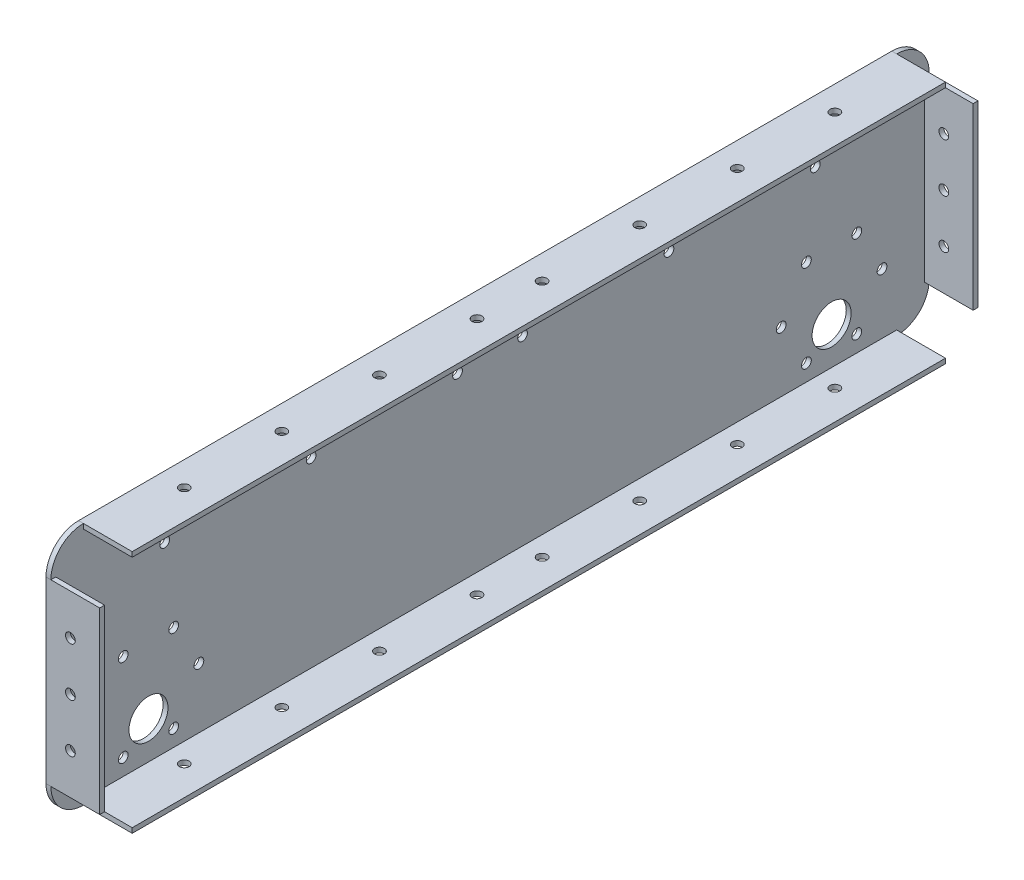
from build123d import *

# Parameters (mm, degrees)
SKETCH1_R           = 1.5
SKETCH1_R_2         = 6
BOSS_EXTRUDE1_DEPTH = 1.5
SKETCH2_W           = 1.5
SKETCH2_H           = 55
BOSS_EXTRUDE2_DEPTH = 15
SKETCH4_R           = 1.5
CUT_EXTRUDE1_DEPTH  = 10
SKETCH6_R           = 1.5
CUT_EXTRUDE2_DEPTH  = 76
SKETCH8_R           = 1.5
CUT_EXTRUDE3_DEPTH  = 271


with BuildPart() as part:
    # Sketch1 → Boss-Extrude1 (new body)
    with BuildSketch(Plane(origin=(0, 0, 0), x_dir=(0, 0, -1), z_dir=(1, 0, 0))):
        with BuildLine():
            Line((-125, 37.5), (125, 37.5))
            ThreePointArc((125, 37.5), (132.071067812, 34.571067812), (135, 27.5))
            Line((135, 27.5), (135, -27.5))
            ThreePointArc((135, -27.5), (132.071067812, -34.571067812), (125, -37.5))
            Line((125, -37.5), (-125, -37.5))
            ThreePointArc((-125, -37.5), (-132.071067812, -34.571067812), (-135, -27.5))
            Line((-135, -27.5), (-135, 27.5))
            ThreePointArc((-135, 27.5), (-132.071067812, 34.571067812), (-125, 37.5))
        make_face()
        with Locations((-112.75, -4.076606241)):
            Circle(SKETCH1_R, mode=Mode.SUBTRACT)
        with Locations((-120.5, -17.5)):
            Circle(SKETCH1_R, mode=Mode.SUBTRACT)
        with Locations((-97.25, -4.076606241)):
            Circle(SKETCH1_R, mode=Mode.SUBTRACT)
        with Locations((-105, -24.5)):
            Circle(SKETCH1_R_2, mode=Mode.SUBTRACT)
        with Locations((-89.5, -17.5)):
            Circle(SKETCH1_R, mode=Mode.SUBTRACT)
        with Locations((-97.25, -30.923393759)):
            Circle(SKETCH1_R, mode=Mode.SUBTRACT)
        with Locations((-112.75, -30.923393759)):
            Circle(SKETCH1_R, mode=Mode.SUBTRACT)
        with Locations((112.75, -30.923393759)):
            Circle(SKETCH1_R, mode=Mode.SUBTRACT)
        with Locations((120.5, -17.5)):
            Circle(SKETCH1_R, mode=Mode.SUBTRACT)
        with Locations((105, -24.5)):
            Circle(SKETCH1_R_2, mode=Mode.SUBTRACT)
        with Locations((97.25, -30.923393759)):
            Circle(SKETCH1_R, mode=Mode.SUBTRACT)
        with Locations((89.5, -17.5)):
            Circle(SKETCH1_R, mode=Mode.SUBTRACT)
        with Locations((97.25, -4.076606241)):
            Circle(SKETCH1_R, mode=Mode.SUBTRACT)
        with Locations((112.75, -4.076606241)):
            Circle(SKETCH1_R, mode=Mode.SUBTRACT)
    extrude(amount=BOSS_EXTRUDE1_DEPTH)

    # Sketch2 → Boss-Extrude2 (add)
    with BuildSketch(Plane(origin=(1.5, 0, 0), x_dir=(0, 0, -1), z_dir=(1, 0, 0))):
        Polygon((-90, 36), (-125, 36), (-125, 37.5), (-90, 37.5), (0, 37.5), (90, 37.5), (125, 37.5), (125, 36), (90, 36), align=None)
        Polygon((90, -37.5), (125, -37.5), (125, -36), (90, -36), (-90, -36), (-125, -36), (-125, -37.5), (-90, -37.5), align=None)
        with Locations((-134.25, 0)):
            Rectangle(SKETCH2_W, SKETCH2_H)
        with Locations((134.25, 0)):
            Rectangle(SKETCH2_W, SKETCH2_H)
    extrude(amount=BOSS_EXTRUDE2_DEPTH)

    # Sketch4 → Cut-Extrude1 (cut)
    with BuildSketch(Plane.ZY):
        with Locations((55, 20)):
            Circle(SKETCH4_R)
        with Locations((10, 20)):
            Circle(SKETCH4_R)
        with Locations((100, 20)):
            Circle(SKETCH4_R)
        with Locations((-10, 20)):
            Circle(SKETCH4_R)
        with Locations((-55, 20)):
            Circle(SKETCH4_R)
        with Locations((-100, 20)):
            Circle(SKETCH4_R)
    extrude(amount=-CUT_EXTRUDE1_DEPTH, mode=Mode.SUBTRACT)

    # Sketch6 → Cut-Extrude2 (cut, through all)
    with BuildSketch(Plane(origin=(0, 37.5, 0), x_dir=(1, 0, 0), z_dir=(0, 1, 0))):
        with Locations((7.5, 10)):
            Circle(SKETCH6_R)
        with Locations((7.5, -10)):
            Circle(SKETCH6_R)
        with Locations((7.5, 40)):
            Circle(SKETCH6_R)
        with Locations((7.5, 70)):
            Circle(SKETCH6_R)
        with Locations((7.5, 100)):
            Circle(SKETCH6_R)
        with Locations((7.5, -40)):
            Circle(SKETCH6_R)
        with Locations((7.5, -70)):
            Circle(SKETCH6_R)
        with Locations((7.5, -100)):
            Circle(SKETCH6_R)
    extrude(amount=-CUT_EXTRUDE2_DEPTH, mode=Mode.SUBTRACT)

    # Sketch8 → Cut-Extrude3 (cut, through all)
    with BuildSketch(Plane.XY.offset(135)):
        with Locations((7.5, 15)):
            Circle(SKETCH8_R)
        with Locations((7.5, 0)):
            Circle(SKETCH8_R)
        with Locations((7.5, -15)):
            Circle(SKETCH8_R)
    extrude(amount=-CUT_EXTRUDE3_DEPTH, mode=Mode.SUBTRACT)


solid = part.part
